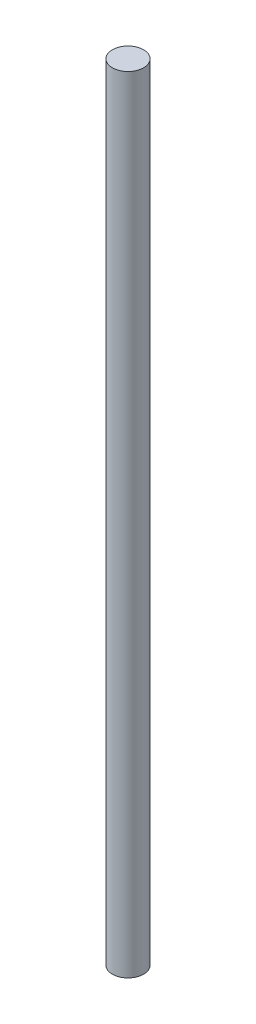
from build123d import *

# Parameters (mm, degrees)
SKETCH1_W = 4.7625
SKETCH1_H = 239


with BuildPart() as part:
    # Sketch1 → Revolve1 (revolve)
    with BuildSketch(Plane.XY):
        with Locations((2.38125, 119.5)):
            Rectangle(SKETCH1_W, SKETCH1_H)
    revolve(axis=Axis((4.7625, 239, 0), (0, -1, 0)))


solid = part.part
